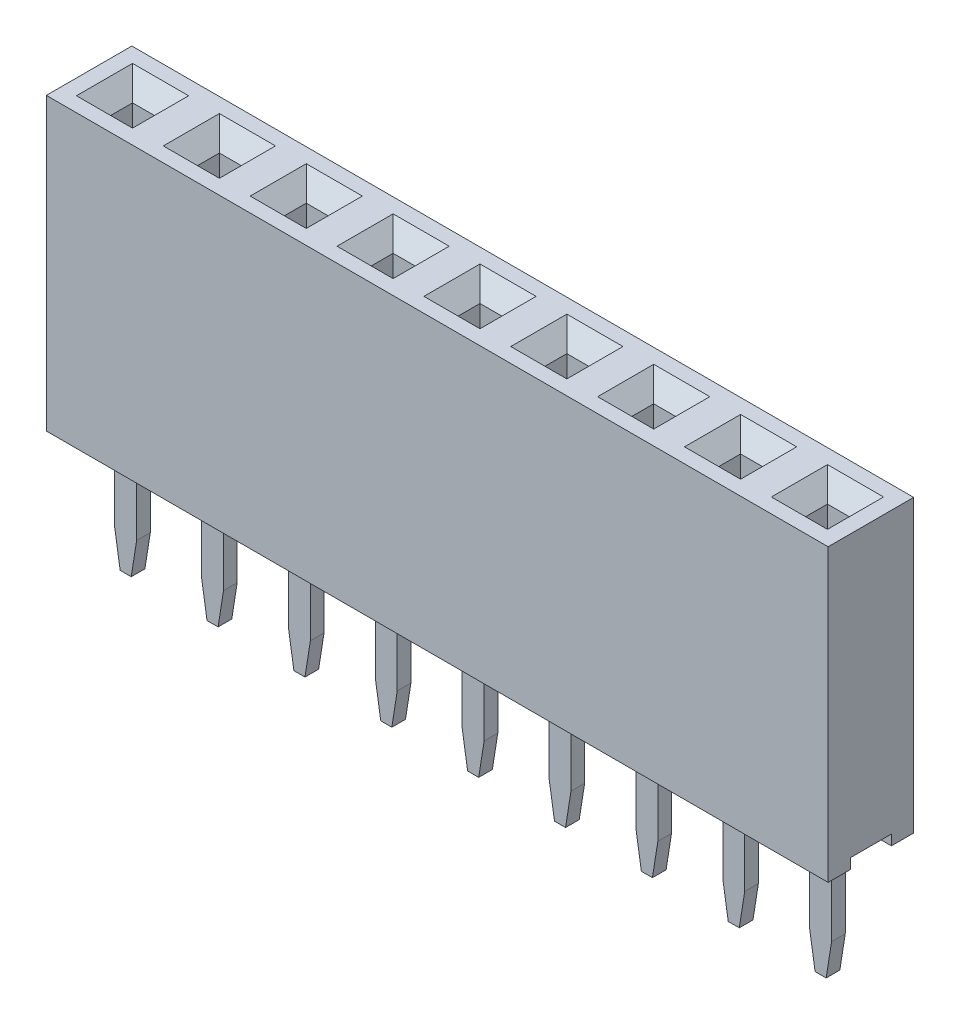
from build123d import *
from OCP.BRepFilletAPI import BRepFilletAPI_MakeChamfer

# Parameters (mm, degrees)
SKETCH1_W                   = 2.54
SKETCH1_H                   = 2.5
BOSS_EXTRUDE1_DEPTH         = 8.5
SKETCH2_W                   = 2.54
SKETCH2_H                   = 1.2
CUT_EXTRUDE1_DEPTH          = 0.3
CUT_EXTRUDE2_START          = -6
SKETCH3_W                   = 0.64
SKETCH3_H                   = 0.64
CUT_EXTRUDE2_DEPTH          = 15.68477979
CHAMFER1_SIZE               = 0.5
SKETCH4_W                   = 0.64
SKETCH4_H                   = 0.4
BOSS_EXTRUDE2_DEPTH         = 3.8
CHAMFER2_SIZE               = 1
CHAMFER2_SIZE2              = 0.15838444
LPATTERN1_COUNT             = 9
LPATTERN1_PITCH             = 2.54
CHAMFER1_OF_LPATTERN1_SIZE  = 0.5
CHAMFER2_OF_LPATTERN1_SIZE  = 1
CHAMFER2_OF_LPATTERN1_SIZE2 = 0.15838444


with BuildPart() as part:
    # Sketch1 → Boss-Extrude1 (new body)
    with BuildSketch(Plane(origin=(0, 0, 0), x_dir=(1, 0, 0), z_dir=(0, 1, 0))):
        Rectangle(SKETCH1_W, SKETCH1_H)
    boss_extrude1 = extrude(amount=BOSS_EXTRUDE1_DEPTH)

    # Sketch2 → Cut-Extrude1 (cut)
    with BuildSketch(Plane.XZ):
        Rectangle(SKETCH2_W, SKETCH2_H)
    cut_extrude1 = extrude(amount=-CUT_EXTRUDE1_DEPTH, mode=Mode.SUBTRACT)

    # Sketch3 → Cut-Extrude2 (cut)
    with BuildSketch(Plane(origin=(0, 8.5, 0), x_dir=(1, 0, 0), z_dir=(0, 1, 0)).offset(CUT_EXTRUDE2_START)):
        Rectangle(SKETCH3_W, SKETCH3_H)
    cut_extrude2 = extrude(amount=CUT_EXTRUDE2_DEPTH, mode=Mode.SUBTRACT)

    # Chamfer1
    chamfer1_edges = [part.edges().sort_by_distance(p)[0] for p in [
        (0, 8.5, 0.32),
        (-0.32, 8.5, 0),
        (0, 8.5, -0.32),
        (0.32, 8.5, 0),
    ]]
    chamfer(chamfer1_edges, length=CHAMFER1_SIZE)

    # Sketch4 → Boss-Extrude2 (add)
    with BuildSketch(Plane.XZ.offset(-0.3)):
        Rectangle(SKETCH4_W, SKETCH4_H)
    boss_extrude2 = extrude(amount=BOSS_EXTRUDE2_DEPTH)

    # Chamfer2: one chamfer whose edges measure the first distance from different faces: ONE call of the kernel's chamfer builder (chamfer() names one face for all edges)
    chamfer2_edges_1 = [part.edges().sort_by_distance(p)[0] for p in [
        (0.32, -3.5, 0),
    ]]
    chamfer2_side_1 = [part.faces().sort_by_distance(p)[0] for p in [
        (0.32, -1.6, 0),
    ]]
    chamfer2_edges_2 = [part.edges().sort_by_distance(p)[0] for p in [
        (-0.32, -3.5, 0),
    ]]
    chamfer2_side_2 = [part.faces().sort_by_distance(p)[0] for p in [
        (-0.32, -1.6, 0),
    ]]
    chamfer2 = BRepFilletAPI_MakeChamfer(part.part.solid().wrapped)
    for e in chamfer2_edges_1:
        chamfer2.Add(CHAMFER2_SIZE, CHAMFER2_SIZE2, e.wrapped, chamfer2_side_1[0].wrapped)  # the first distance lies on this face
    for e in chamfer2_edges_2:
        chamfer2.Add(CHAMFER2_SIZE, CHAMFER2_SIZE2, e.wrapped, chamfer2_side_2[0].wrapped)  # the first distance lies on this face
    add(Compound.cast(chamfer2.Shape()), mode=Mode.REPLACE)

    # LPattern1: Boss-Extrude1, Cut-Extrude1, Cut-Extrude2, Boss-Extrude2 ×9
    with Locations(*[(-i * LPATTERN1_PITCH, 0, 0) for i in range(1, LPATTERN1_COUNT)]):
        add(boss_extrude1)
        add(cut_extrude1, mode=Mode.SUBTRACT)
        add(cut_extrude2, mode=Mode.SUBTRACT)
        add(boss_extrude2)

    # Chamfer1 of LPattern1
    chamfer1_of_lpattern1_edges = [part.edges().sort_by_distance(p)[0] for p in [
        (-2.54, 8.5, 0.32),
        (-2.86, 8.5, 0),
        (-2.54, 8.5, -0.32),
        (-2.22, 8.5, 0),
        (-5.08, 8.5, 0.32),
        (-5.4, 8.5, 0),
        (-5.08, 8.5, -0.32),
        (-4.76, 8.5, 0),
        (-7.62, 8.5, 0.32),
        (-7.94, 8.5, 0),
        (-7.62, 8.5, -0.32),
        (-7.3, 8.5, 0),
        (-10.16, 8.5, 0.32),
        (-10.48, 8.5, 0),
        (-10.16, 8.5, -0.32),
        (-9.84, 8.5, 0),
        (-12.7, 8.5, 0.32),
        (-13.02, 8.5, 0),
        (-12.7, 8.5, -0.32),
        (-12.38, 8.5, 0),
        (-15.24, 8.5, 0.32),
        (-15.56, 8.5, 0),
        (-15.24, 8.5, -0.32),
        (-14.92, 8.5, 0),
        (-17.78, 8.5, 0.32),
        (-18.1, 8.5, 0),
        (-17.78, 8.5, -0.32),
        (-17.46, 8.5, 0),
        (-20.32, 8.5, 0.32),
        (-20.64, 8.5, 0),
        (-20.32, 8.5, -0.32),
        (-20, 8.5, 0),
    ]]
    chamfer(chamfer1_of_lpattern1_edges, length=CHAMFER1_OF_LPATTERN1_SIZE)

    # Chamfer2 of LPattern1: one chamfer whose edges measure the first distance from different faces: ONE call of the kernel's chamfer builder (chamfer() names one face for all edges)
    chamfer2_of_lpattern1_edges_1 = [part.edges().sort_by_distance(p)[0] for p in [
        (-2.22, -3.5, 0),
    ]]
    chamfer2_of_lpattern1_side_1 = [part.faces().sort_by_distance(p)[0] for p in [
        (-2.22, -1.6, 0),
    ]]
    chamfer2_of_lpattern1_edges_2 = [part.edges().sort_by_distance(p)[0] for p in [
        (-2.86, -3.5, 0),
    ]]
    chamfer2_of_lpattern1_side_2 = [part.faces().sort_by_distance(p)[0] for p in [
        (-2.86, -1.6, 0),
    ]]
    chamfer2_of_lpattern1_edges_3 = [part.edges().sort_by_distance(p)[0] for p in [
        (-4.76, -3.5, 0),
    ]]
    chamfer2_of_lpattern1_side_3 = [part.faces().sort_by_distance(p)[0] for p in [
        (-4.76, -1.6, 0),
    ]]
    chamfer2_of_lpattern1_edges_4 = [part.edges().sort_by_distance(p)[0] for p in [
        (-5.4, -3.5, 0),
    ]]
    chamfer2_of_lpattern1_side_4 = [part.faces().sort_by_distance(p)[0] for p in [
        (-5.4, -1.6, 0),
    ]]
    chamfer2_of_lpattern1_edges_5 = [part.edges().sort_by_distance(p)[0] for p in [
        (-7.3, -3.5, 0),
    ]]
    chamfer2_of_lpattern1_side_5 = [part.faces().sort_by_distance(p)[0] for p in [
        (-7.3, -1.6, 0),
    ]]
    chamfer2_of_lpattern1_edges_6 = [part.edges().sort_by_distance(p)[0] for p in [
        (-7.94, -3.5, 0),
    ]]
    chamfer2_of_lpattern1_side_6 = [part.faces().sort_by_distance(p)[0] for p in [
        (-7.94, -1.6, 0),
    ]]
    chamfer2_of_lpattern1_edges_7 = [part.edges().sort_by_distance(p)[0] for p in [
        (-9.84, -3.5, 0),
    ]]
    chamfer2_of_lpattern1_side_7 = [part.faces().sort_by_distance(p)[0] for p in [
        (-9.84, -1.6, 0),
    ]]
    chamfer2_of_lpattern1_edges_8 = [part.edges().sort_by_distance(p)[0] for p in [
        (-10.48, -3.5, 0),
    ]]
    chamfer2_of_lpattern1_side_8 = [part.faces().sort_by_distance(p)[0] for p in [
        (-10.48, -1.6, 0),
    ]]
    chamfer2_of_lpattern1_edges_9 = [part.edges().sort_by_distance(p)[0] for p in [
        (-12.38, -3.5, 0),
    ]]
    chamfer2_of_lpattern1_side_9 = [part.faces().sort_by_distance(p)[0] for p in [
        (-12.38, -1.6, 0),
    ]]
    chamfer2_of_lpattern1_edges_10 = [part.edges().sort_by_distance(p)[0] for p in [
        (-13.02, -3.5, 0),
    ]]
    chamfer2_of_lpattern1_side_10 = [part.faces().sort_by_distance(p)[0] for p in [
        (-13.02, -1.6, 0),
    ]]
    chamfer2_of_lpattern1_edges_11 = [part.edges().sort_by_distance(p)[0] for p in [
        (-14.92, -3.5, 0),
    ]]
    chamfer2_of_lpattern1_side_11 = [part.faces().sort_by_distance(p)[0] for p in [
        (-14.92, -1.6, 0),
    ]]
    chamfer2_of_lpattern1_edges_12 = [part.edges().sort_by_distance(p)[0] for p in [
        (-15.56, -3.5, 0),
    ]]
    chamfer2_of_lpattern1_side_12 = [part.faces().sort_by_distance(p)[0] for p in [
        (-15.56, -1.6, 0),
    ]]
    chamfer2_of_lpattern1_edges_13 = [part.edges().sort_by_distance(p)[0] for p in [
        (-17.46, -3.5, 0),
    ]]
    chamfer2_of_lpattern1_side_13 = [part.faces().sort_by_distance(p)[0] for p in [
        (-17.46, -1.6, 0),
    ]]
    chamfer2_of_lpattern1_edges_14 = [part.edges().sort_by_distance(p)[0] for p in [
        (-18.1, -3.5, 0),
    ]]
    chamfer2_of_lpattern1_side_14 = [part.faces().sort_by_distance(p)[0] for p in [
        (-18.1, -1.6, 0),
    ]]
    chamfer2_of_lpattern1_edges_15 = [part.edges().sort_by_distance(p)[0] for p in [
        (-20, -3.5, 0),
    ]]
    chamfer2_of_lpattern1_side_15 = [part.faces().sort_by_distance(p)[0] for p in [
        (-20, -1.6, 0),
    ]]
    chamfer2_of_lpattern1_edges_16 = [part.edges().sort_by_distance(p)[0] for p in [
        (-20.64, -3.5, 0),
    ]]
    chamfer2_of_lpattern1_side_16 = [part.faces().sort_by_distance(p)[0] for p in [
        (-20.64, -1.6, 0),
    ]]
    chamfer2_of_lpattern1 = BRepFilletAPI_MakeChamfer(part.part.solid().wrapped)
    for e in chamfer2_of_lpattern1_edges_1:
        chamfer2_of_lpattern1.Add(CHAMFER2_OF_LPATTERN1_SIZE, CHAMFER2_OF_LPATTERN1_SIZE2, e.wrapped, chamfer2_of_lpattern1_side_1[0].wrapped)  # the first distance lies on this face
    for e in chamfer2_of_lpattern1_edges_2:
        chamfer2_of_lpattern1.Add(CHAMFER2_OF_LPATTERN1_SIZE, CHAMFER2_OF_LPATTERN1_SIZE2, e.wrapped, chamfer2_of_lpattern1_side_2[0].wrapped)  # the first distance lies on this face
    for e in chamfer2_of_lpattern1_edges_3:
        chamfer2_of_lpattern1.Add(CHAMFER2_OF_LPATTERN1_SIZE, CHAMFER2_OF_LPATTERN1_SIZE2, e.wrapped, chamfer2_of_lpattern1_side_3[0].wrapped)  # the first distance lies on this face
    for e in chamfer2_of_lpattern1_edges_4:
        chamfer2_of_lpattern1.Add(CHAMFER2_OF_LPATTERN1_SIZE, CHAMFER2_OF_LPATTERN1_SIZE2, e.wrapped, chamfer2_of_lpattern1_side_4[0].wrapped)  # the first distance lies on this face
    for e in chamfer2_of_lpattern1_edges_5:
        chamfer2_of_lpattern1.Add(CHAMFER2_OF_LPATTERN1_SIZE, CHAMFER2_OF_LPATTERN1_SIZE2, e.wrapped, chamfer2_of_lpattern1_side_5[0].wrapped)  # the first distance lies on this face
    for e in chamfer2_of_lpattern1_edges_6:
        chamfer2_of_lpattern1.Add(CHAMFER2_OF_LPATTERN1_SIZE, CHAMFER2_OF_LPATTERN1_SIZE2, e.wrapped, chamfer2_of_lpattern1_side_6[0].wrapped)  # the first distance lies on this face
    for e in chamfer2_of_lpattern1_edges_7:
        chamfer2_of_lpattern1.Add(CHAMFER2_OF_LPATTERN1_SIZE, CHAMFER2_OF_LPATTERN1_SIZE2, e.wrapped, chamfer2_of_lpattern1_side_7[0].wrapped)  # the first distance lies on this face
    for e in chamfer2_of_lpattern1_edges_8:
        chamfer2_of_lpattern1.Add(CHAMFER2_OF_LPATTERN1_SIZE, CHAMFER2_OF_LPATTERN1_SIZE2, e.wrapped, chamfer2_of_lpattern1_side_8[0].wrapped)  # the first distance lies on this face
    for e in chamfer2_of_lpattern1_edges_9:
        chamfer2_of_lpattern1.Add(CHAMFER2_OF_LPATTERN1_SIZE, CHAMFER2_OF_LPATTERN1_SIZE2, e.wrapped, chamfer2_of_lpattern1_side_9[0].wrapped)  # the first distance lies on this face
    for e in chamfer2_of_lpattern1_edges_10:
        chamfer2_of_lpattern1.Add(CHAMFER2_OF_LPATTERN1_SIZE, CHAMFER2_OF_LPATTERN1_SIZE2, e.wrapped, chamfer2_of_lpattern1_side_10[0].wrapped)  # the first distance lies on this face
    for e in chamfer2_of_lpattern1_edges_11:
        chamfer2_of_lpattern1.Add(CHAMFER2_OF_LPATTERN1_SIZE, CHAMFER2_OF_LPATTERN1_SIZE2, e.wrapped, chamfer2_of_lpattern1_side_11[0].wrapped)  # the first distance lies on this face
    for e in chamfer2_of_lpattern1_edges_12:
        chamfer2_of_lpattern1.Add(CHAMFER2_OF_LPATTERN1_SIZE, CHAMFER2_OF_LPATTERN1_SIZE2, e.wrapped, chamfer2_of_lpattern1_side_12[0].wrapped)  # the first distance lies on this face
    for e in chamfer2_of_lpattern1_edges_13:
        chamfer2_of_lpattern1.Add(CHAMFER2_OF_LPATTERN1_SIZE, CHAMFER2_OF_LPATTERN1_SIZE2, e.wrapped, chamfer2_of_lpattern1_side_13[0].wrapped)  # the first distance lies on this face
    for e in chamfer2_of_lpattern1_edges_14:
        chamfer2_of_lpattern1.Add(CHAMFER2_OF_LPATTERN1_SIZE, CHAMFER2_OF_LPATTERN1_SIZE2, e.wrapped, chamfer2_of_lpattern1_side_14[0].wrapped)  # the first distance lies on this face
    for e in chamfer2_of_lpattern1_edges_15:
        chamfer2_of_lpattern1.Add(CHAMFER2_OF_LPATTERN1_SIZE, CHAMFER2_OF_LPATTERN1_SIZE2, e.wrapped, chamfer2_of_lpattern1_side_15[0].wrapped)  # the first distance lies on this face
    for e in chamfer2_of_lpattern1_edges_16:
        chamfer2_of_lpattern1.Add(CHAMFER2_OF_LPATTERN1_SIZE, CHAMFER2_OF_LPATTERN1_SIZE2, e.wrapped, chamfer2_of_lpattern1_side_16[0].wrapped)  # the first distance lies on this face
    add(Compound.cast(chamfer2_of_lpattern1.Shape()), mode=Mode.REPLACE)


solid = part.part
